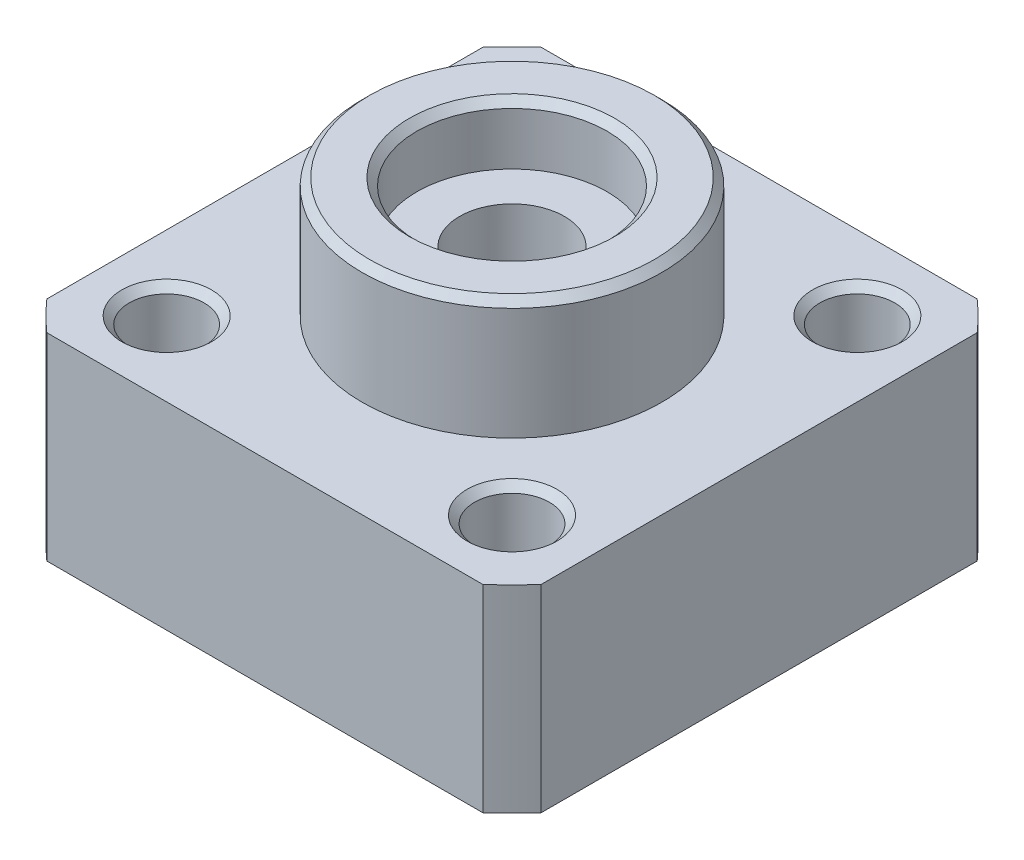
from build123d import *

# Parameters (mm, degrees)
SKETCH3_W               = 61.087252859
SKETCH3_H               = 56.880141781
SKETCH3_W_2             = 33
SKETCH3_H_2             = 33
CUT_EXTRUDE1_DEPTH      = 22.2
SKETCH6_R               = 2.5
CUT_EXTRUDE5_DEPTH      = 22.2
CUT_EXTRUDE3_REACH      = 35
SKETCH5_R               = 2
G1_8_TAPPED_HOLE1_D     = 8.8
G1_8_TAPPED_HOLE1_DEPTH = 9.356213276
G1_8_TAPPED_HOLE1_TIP   = 2.643786724
CHAMFER1_SIZE           = 0.5


with BuildPart() as part:
    # Sketch2 → Revolve1 (revolve)
    with BuildSketch(Plane.XY):
        Polygon((-3.5, 0), (-22, 0), (-22, 13.2), (-10, 13.2), (-10, 21.2), (-6.35, 21.2), (-6.35, 17.2), (-3.5, 17.2), align=None)
    revolve(axis=Axis((0, 0, 0), (0, 1, 0)))

    # Sketch3 → Cut-Extrude1 (cut, through all)
    with BuildSketch(Plane.XZ):
        with Locations((1.009706659, -0.631066662)):
            Rectangle(SKETCH3_W, SKETCH3_H)
        Rectangle(SKETCH3_W_2, SKETCH3_H_2, mode=Mode.SUBTRACT)
    extrude(amount=-CUT_EXTRUDE1_DEPTH, mode=Mode.SUBTRACT)

    # Sketch6 → Cut-Extrude5 (cut, through all)
    with BuildSketch(Plane.XZ):
        with Locations((-11.525840533, 11.525840533)):
            Circle(SKETCH6_R)
        with Locations((11.525840533, 11.525840533)):
            Circle(SKETCH6_R)
        with Locations((-11.525840533, -11.525840533)):
            Circle(SKETCH6_R)
        with Locations((11.525840533, -11.525840533)):
            Circle(SKETCH6_R)
    extrude(amount=-CUT_EXTRUDE5_DEPTH, mode=Mode.SUBTRACT)

    # Sketch5 → Cut-Extrude3 (cut, up to next)
    with BuildSketch(Plane(origin=(0, 0, -16.5), x_dir=(-1, 0, 0), z_dir=(0, 0, -1)), mode=Mode.PRIVATE) as cut_extrude3_sk1:
        with Locations((0, 6.6)):
            Circle(SKETCH5_R)
    cut_extrude3_tool1 = extrude(cut_extrude3_sk1.sketch, amount=-CUT_EXTRUDE3_REACH, mode=Mode.PRIVATE) & part.part
    add(cut_extrude3_tool1.solids().sort_by_distance((0, 6.6, -16.5))[0], mode=Mode.SUBTRACT)

    # G1/8 Tapped Hole1
    with Locations(Plane(origin=(0, 6.6, -16.5), x_dir=(-1, 0, 0), z_dir=(0, 0, -1))):
        with Locations((0, 0)):
            Hole(G1_8_TAPPED_HOLE1_D / 2, depth=G1_8_TAPPED_HOLE1_DEPTH)
            with Locations((0, 0, -(G1_8_TAPPED_HOLE1_DEPTH + G1_8_TAPPED_HOLE1_TIP / 2))):  # 118° drill point
                Cone(0, G1_8_TAPPED_HOLE1_D / 2, G1_8_TAPPED_HOLE1_TIP, mode=Mode.SUBTRACT)

    # Chamfer1
    chamfer1_edges = [part.edges().sort_by_distance(p)[0] for p in [
        (6.35, 21.2, 0),
        (3.5, 0, 0),
        (-14.025840533, 13.2, -11.525840533),
        (-14.025840533, 0, -11.525840533),
        (9.025840533, 13.2, 11.525840533),
        (9.025840533, 0, 11.525840533),
        (9.025840533, 13.2, -11.525840533),
        (9.025840533, 0, -11.525840533),
        (-14.025840533, 13.2, 11.525840533),
        (-14.025840533, 0, 11.525840533),
        (10, 21.2, 0),
    ]]
    chamfer(chamfer1_edges, length=CHAMFER1_SIZE)


solid = part.part
